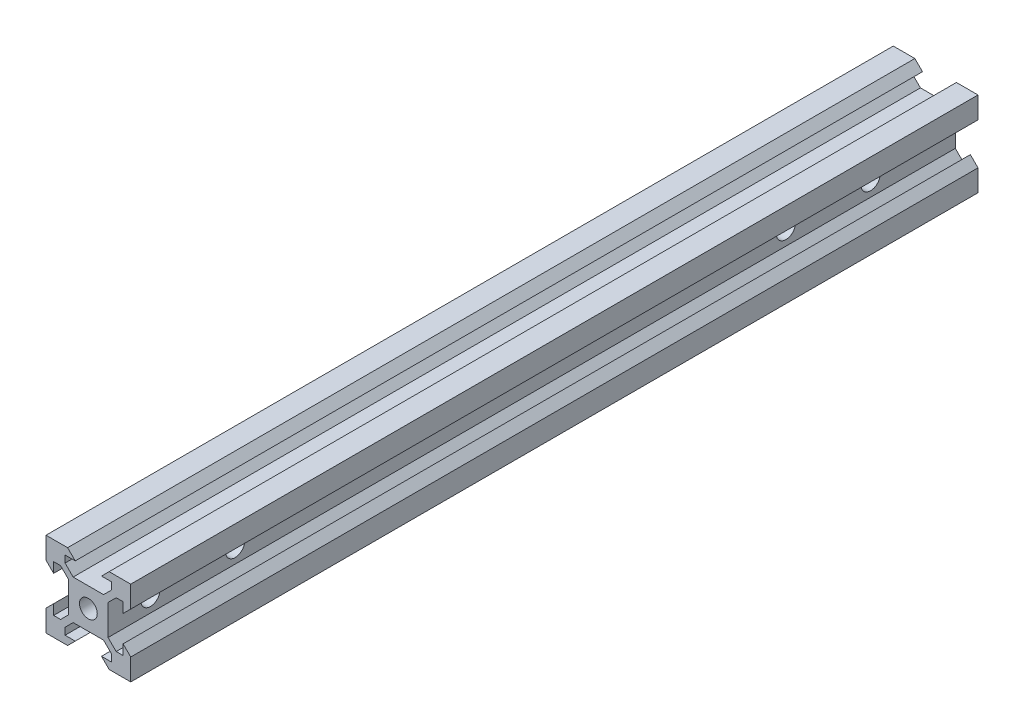
from build123d import *

# Parameters (mm, degrees)
SKETCH1_R           = 2.1
BOSS_EXTRUDE1_DEPTH = 100
CUT_EXTRUDE1_REACH  = 16.651
SKETCH3_R           = 2.25


with BuildPart() as part:
    # Sketch1 → Boss-Extrude1 (new body, symmetric)
    with BuildSketch(Plane.XY):
        Polygon((5.499339828, 6.56), (3.59, 4.650660172), (-3.59, 4.650660172), (-5.499339828, 6.56), (-5.499339828, 8.2), (-3.1, 8.2), (-4.9, 10), (-10, 10), (-10, 4.9), (-8.2, 3.1), (-8.2, 5.499339828), (-6.56, 5.499339828), (-4.650660172, 3.59), (-4.650660172, -3.59), (-6.56, -5.499339828), (-8.2, -5.499339828), (-8.2, -3.1), (-10, -4.9), (-10, -10), (-4.9, -10), (-3.1, -8.2), (-5.499339828, -8.2), (-5.499339828, -6.56), (-3.59, -4.650660172), (3.59, -4.650660172), (5.499339828, -6.56), (5.499339828, -8.2), (3.1, -8.2), (4.9, -10), (10, -10), (10, -4.9), (8.2, -3.1), (8.2, -5.499339828), (6.56, -5.499339828), (4.650660172, -3.59), (4.650660172, 3.59), (6.56, 5.499339828), (8.2, 5.499339828), (8.2, 3.1), (10, 4.9), (10, 10), (4.9, 10), (3.1, 8.2), (5.499339828, 8.2), align=None)
        Circle(SKETCH1_R, mode=Mode.SUBTRACT)
    extrude(amount=BOSS_EXTRUDE1_DEPTH, both=True)

    # Sketch3 → Cut-Extrude1 (cut, up to next)
    with BuildSketch(Plane(origin=(4.650660172, 0, 0), x_dir=(0, 0, -1), z_dir=(1, 0, 0)), mode=Mode.PRIVATE) as cut_extrude1_sk1:
        with Locations((-90, 0)):
            Circle(SKETCH3_R)
    cut_extrude1_tool1 = extrude(cut_extrude1_sk1.sketch, amount=-CUT_EXTRUDE1_REACH, mode=Mode.PRIVATE) & part.part
    add(cut_extrude1_tool1.solids().sort_by_distance((4.65066, 0, 90))[0], mode=Mode.SUBTRACT)
    # Sketch3 → Cut-Extrude1 (cut, up to next)
    with BuildSketch(Plane(origin=(4.650660172, 0, 0), x_dir=(0, 0, -1), z_dir=(1, 0, 0)), mode=Mode.PRIVATE) as cut_extrude1_sk2:
        with Locations((-70, 0)):
            Circle(SKETCH3_R)
    cut_extrude1_tool2 = extrude(cut_extrude1_sk2.sketch, amount=-CUT_EXTRUDE1_REACH, mode=Mode.PRIVATE) & part.part
    add(cut_extrude1_tool2.solids().sort_by_distance((4.65066, 0, 70))[0], mode=Mode.SUBTRACT)
    # Sketch3 → Cut-Extrude1 (cut, up to next)
    with BuildSketch(Plane(origin=(4.650660172, 0, 0), x_dir=(0, 0, -1), z_dir=(1, 0, 0)), mode=Mode.PRIVATE) as cut_extrude1_sk3:
        with Locations((60, 0)):
            Circle(SKETCH3_R)
    cut_extrude1_tool3 = extrude(cut_extrude1_sk3.sketch, amount=-CUT_EXTRUDE1_REACH, mode=Mode.PRIVATE) & part.part
    add(cut_extrude1_tool3.solids().sort_by_distance((4.65066, 0, -60))[0], mode=Mode.SUBTRACT)
    # Sketch3 → Cut-Extrude1 (cut, up to next)
    with BuildSketch(Plane(origin=(4.650660172, 0, 0), x_dir=(0, 0, -1), z_dir=(1, 0, 0)), mode=Mode.PRIVATE) as cut_extrude1_sk4:
        with Locations((80, 0)):
            Circle(SKETCH3_R)
    cut_extrude1_tool4 = extrude(cut_extrude1_sk4.sketch, amount=-CUT_EXTRUDE1_REACH, mode=Mode.PRIVATE) & part.part
    add(cut_extrude1_tool4.solids().sort_by_distance((4.65066, 0, -80))[0], mode=Mode.SUBTRACT)


solid = part.part
